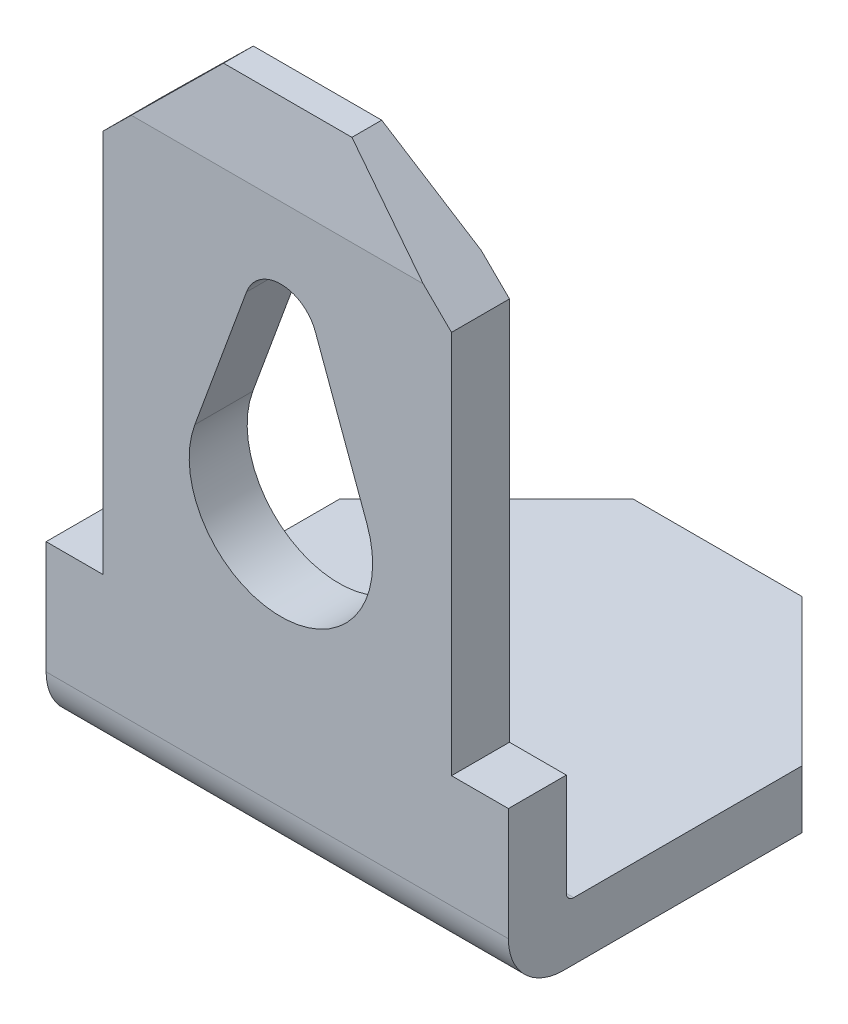
from build123d import *

# Parameters (mm, degrees)
BOSS_EXTRUDE1_DEPTH     = 6.3
CHAMFER3_SIZE           = 2
CUT_EXTRUDE2_DEPTH      = 0.79
SKETCH6_W               = 0.775
SKETCH6_H               = 6.713276343
CUT_EXTRUDE4_DEPTH      = 0.79
CUT_EXTRUDE6_DEPTH      = 1.79
CUT_EXTRUDE6_DEPTH_BACK = 6.21


with BuildPart() as part:
    # Sketch1 → Boss-Extrude1 (new body)
    with BuildSketch(Plane(origin=(0, 0, 0), x_dir=(0, 0, -1), z_dir=(1, 0, 0))):
        with BuildLine():
            Line((0, 0.1), (0, 7.11))
            Line((0, 7.11), (-0.241393443, 8.21))
            Line((-0.241393443, 8.21), (-0.647131148, 8.21))
            Line((-0.647131148, 8.21), (-0.79, 7.11))
            Line((-0.79, 7.11), (-0.79, -0.04))
            ThreePointArc((-0.79, -0.04), (-0.570330086, -0.570330086), (-0.04, -0.79))
            Line((-0.04, -0.79), (5.21, -0.79))
            Line((5.21, -0.79), (5.21, 0))
            Line((5.21, 0), (0.1, 0))
            ThreePointArc((0.1, 0), (0.029289322, 0.029289322), (0, 0.1))
        make_face()
    extrude(amount=BOSS_EXTRUDE1_DEPTH)

    # Chamfer3
    chamfer3_edges = [part.edges().sort_by_distance(p)[0] for p in [
        (0, -0.395, -5.21),
        (6.3, -0.395, -5.21),
    ]]
    chamfer(chamfer3_edges, length=CHAMFER3_SIZE)

    # Sketch5 → Cut-Extrude2 (cut)
    with BuildSketch(Plane.XY.offset(0.79)):
        with BuildLine():
            Line((2.730622244, 5.808829869), (2.026555611, 3.890729922))
            ThreePointArc((2.026555611, 3.890729922), (3.20000017, 2.21), (4.373444272, 3.890730241))
            Line((4.373444272, 3.890730241), (3.669633952, 5.808130298))
            ThreePointArc((3.669633952, 5.808130298), (3.200372504, 6.136537762), (2.730622244, 5.808829869))
        make_face()
    extrude(amount=-CUT_EXTRUDE2_DEPTH, mode=Mode.SUBTRACT)

    # Sketch6 → Cut-Extrude4 (cut)
    with BuildSketch(Plane(origin=(0, 0, 0), x_dir=(-1, 0, 0), z_dir=(0, 0, -1))):
        with Locations((-5.9125, 4.853361829)):
            Rectangle(SKETCH6_W, SKETCH6_H)
        with Locations((-0.3875, 4.853361829)):
            Rectangle(SKETCH6_W, SKETCH6_H)
    extrude(amount=-CUT_EXTRUDE4_DEPTH, mode=Mode.SUBTRACT)

    # Sketch4 → Cut-Extrude6 (cut, two sides)
    with BuildSketch(Plane.XY) as cut_extrude6_sk:
        Polygon((2.275, 8.21), (0.775, 8.21), (0.755504439, 6.71), align=None)
        Polygon((5.544495561, 6.71), (4.025, 8.21), (5.525, 8.21), align=None)
    extrude(amount=CUT_EXTRUDE6_DEPTH, mode=Mode.SUBTRACT)
    extrude(cut_extrude6_sk.sketch, amount=-CUT_EXTRUDE6_DEPTH_BACK, mode=Mode.SUBTRACT)


solid = part.part
